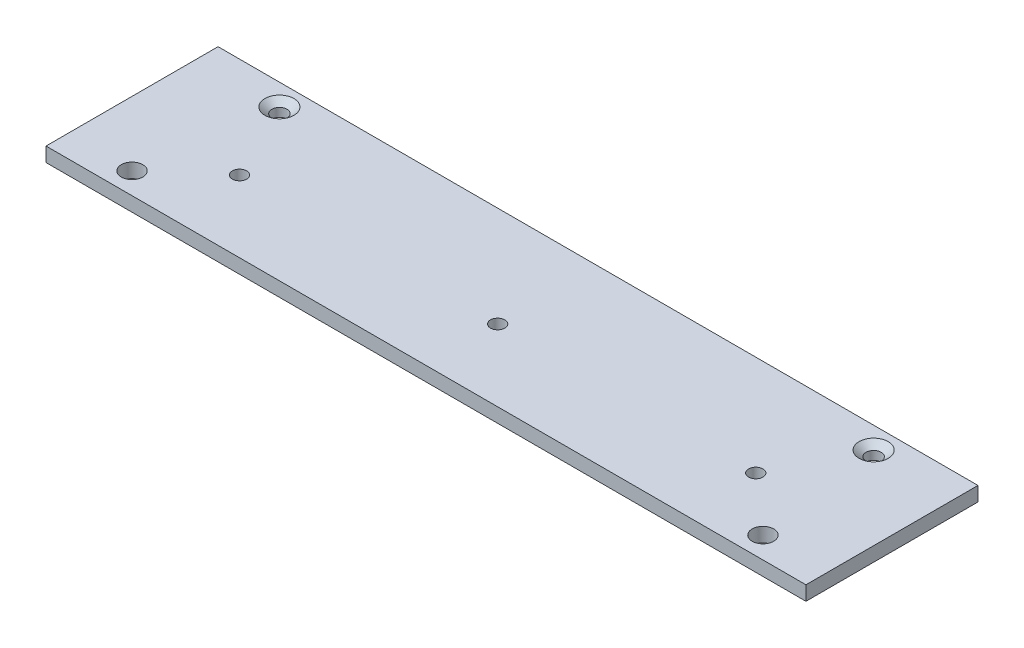
from build123d import *

# Parameters (mm, degrees)
SKETCH1_W                                           = 336.55
SKETCH1_H                                           = 76.2
SKETCH1_R                                           = 4.7625
SKETCH1_R_2                                         = 3.175
BOSS_EXTRUDE1_DEPTH                                 = 3.175
CSK_FOR_1_4_FLAT_HEAD_MACHINE_SCREW_100_D           = 6.7564
CSK_FOR_1_4_FLAT_HEAD_MACHINE_SCREW_100_CSINK_D     = 12.8778
CSK_FOR_1_4_FLAT_HEAD_MACHINE_SCREW_100_CSINK_ANGLE = 100
SKETCH5_R                                           = 3.175
CUT_EXTRUDE2_DEPTH                                  = 1
CUT_EXTRUDE2_DEPTH_BACK                             = 7.35


with BuildPart() as part:
    # Sketch1 → Boss-Extrude1 (new body, symmetric)
    with BuildSketch(Plane(origin=(0, 0, 0), x_dir=(1, 0, 0), z_dir=(0, 1, 0))):
        with Locations((0, 12.7)):
            Rectangle(SKETCH1_W, SKETCH1_H)
        with Locations((-139.7, -15.875)):
            Circle(SKETCH1_R, mode=Mode.SUBTRACT)
        with Locations((139.7, -15.875)):
            Circle(SKETCH1_R, mode=Mode.SUBTRACT)
        with Locations((131.572, 41.275)):
            Circle(SKETCH1_R_2, mode=Mode.SUBTRACT)
        with Locations((-131.572, 41.275)):
            Circle(SKETCH1_R_2, mode=Mode.SUBTRACT)
    extrude(amount=BOSS_EXTRUDE1_DEPTH, both=True)

    # CSK for 1/4 Flat Head Machine Screw (100)1 (through all)
    with Locations(Plane(origin=(0, 3.175, 0), x_dir=(1, 0, 0), z_dir=(0, 1, 0))):
        with Locations((-131.572, 41.275), (131.572, 41.275)):
            CounterSinkHole(CSK_FOR_1_4_FLAT_HEAD_MACHINE_SCREW_100_D / 2, CSK_FOR_1_4_FLAT_HEAD_MACHINE_SCREW_100_CSINK_D / 2, counter_sink_angle=CSK_FOR_1_4_FLAT_HEAD_MACHINE_SCREW_100_CSINK_ANGLE)

    # Sketch5 → Cut-Extrude2 (cut, two sides)
    with BuildSketch(Plane(origin=(0, 3.175, 0), x_dir=(1, 0, 0), z_dir=(0, 1, 0))) as cut_extrude2_sk:
        with Locations((-114.3, 6.35)):
            Circle(SKETCH5_R)
        with Locations((114.3, 6.35)):
            Circle(SKETCH5_R)
        with Locations((0, 6.35)):
            Circle(SKETCH5_R)
    extrude(amount=CUT_EXTRUDE2_DEPTH, mode=Mode.SUBTRACT)
    extrude(cut_extrude2_sk.sketch, amount=-CUT_EXTRUDE2_DEPTH_BACK, mode=Mode.SUBTRACT)


solid = part.part
